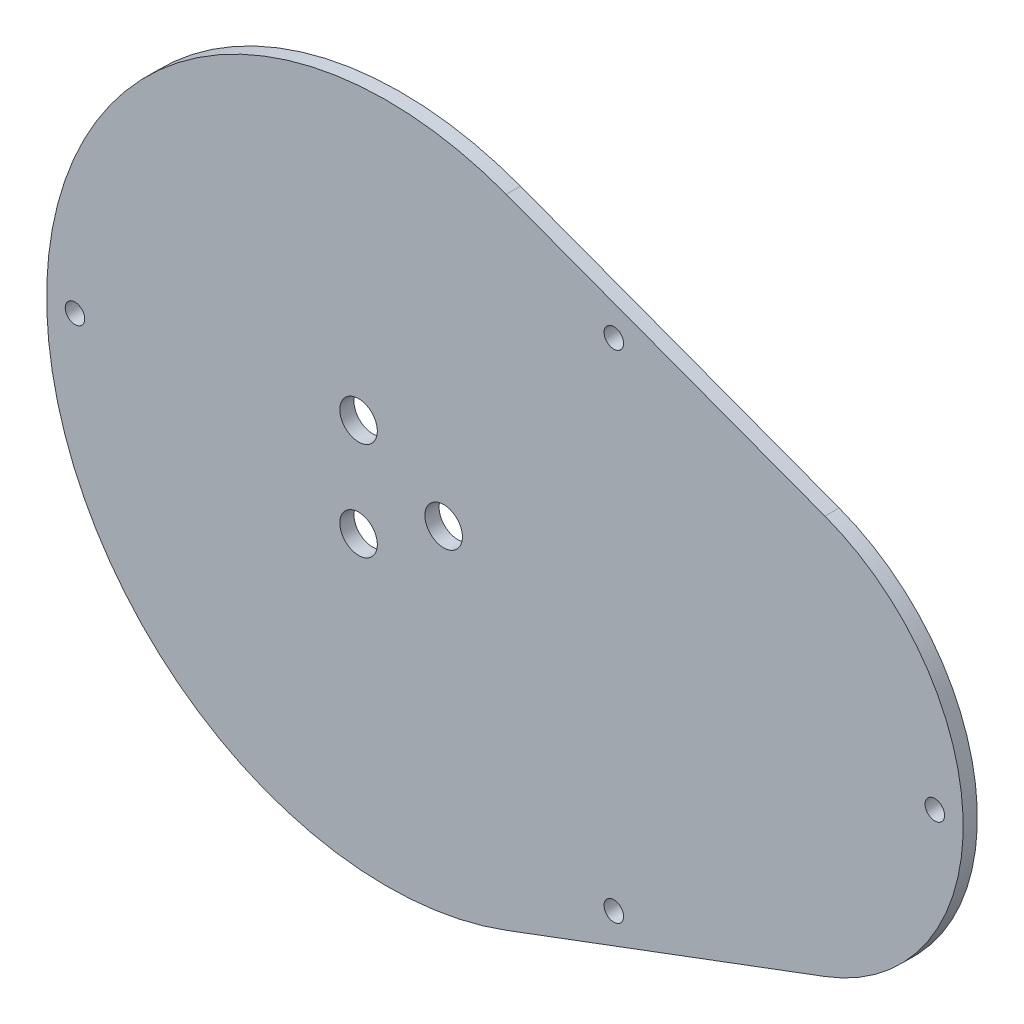
from build123d import *

# Parameters (mm, degrees)
SKETCH1_R           = 1.0922
SKETCH1_R_2         = 2.1
BOSS_EXTRUDE1_DEPTH = 1.5875


with BuildPart() as part:
    # Sketch1 → Boss-Extrude1 (new body)
    with BuildSketch(Plane.XY):
        with BuildLine():
            Line((13.360883802, 35.680481836), (49.041365638, 22.319598034))
            ThreePointArc((49.041365638, 22.319598034), (64.516692787, 0), (49.041365638, -22.319598034))
            Line((49.041365638, -22.319598034), (13.360883802, -35.680481836))
            ThreePointArc((13.360883802, -35.680481836), (-38.1, 0), (13.360883802, 35.680481836))
        make_face()
        with Locations((61.341692787, 0)):
            Circle(SKETCH1_R, mode=Mode.SUBTRACT)
        with Locations((25.4, 27.782025366)):
            Circle(SKETCH1_R, mode=Mode.SUBTRACT)
        with Locations((25.4, -27.782025366)):
            Circle(SKETCH1_R, mode=Mode.SUBTRACT)
        with Locations((-34.925, 0)):
            Circle(SKETCH1_R, mode=Mode.SUBTRACT)
        with Locations((6.35, 0)):
            Circle(SKETCH1_R_2, mode=Mode.SUBTRACT)
        with Locations((-3.175, -5.499261314)):
            Circle(SKETCH1_R_2, mode=Mode.SUBTRACT)
        with Locations((-3.175, 5.499261314)):
            Circle(SKETCH1_R_2, mode=Mode.SUBTRACT)
    extrude(amount=BOSS_EXTRUDE1_DEPTH)


solid = part.part
